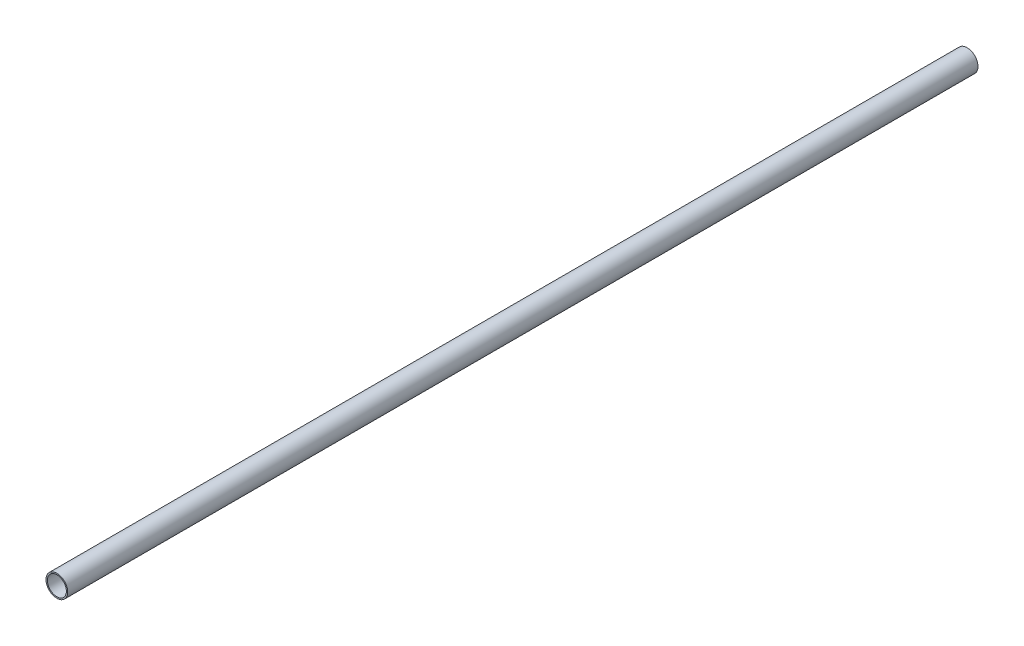
from build123d import *

# Parameters (mm, degrees)
ESQUISSE1_R        = 4
ESQUISSE1_R_2      = 3.5
BOSS_EXTRU_1_DEPTH = 335


with BuildPart() as part:
    # Esquisse1 → Boss.-Extru.1 (new body)
    with BuildSketch(Plane.XY):
        Circle(ESQUISSE1_R)
        Circle(ESQUISSE1_R_2, mode=Mode.SUBTRACT)
    extrude(amount=BOSS_EXTRU_1_DEPTH)


solid = part.part
